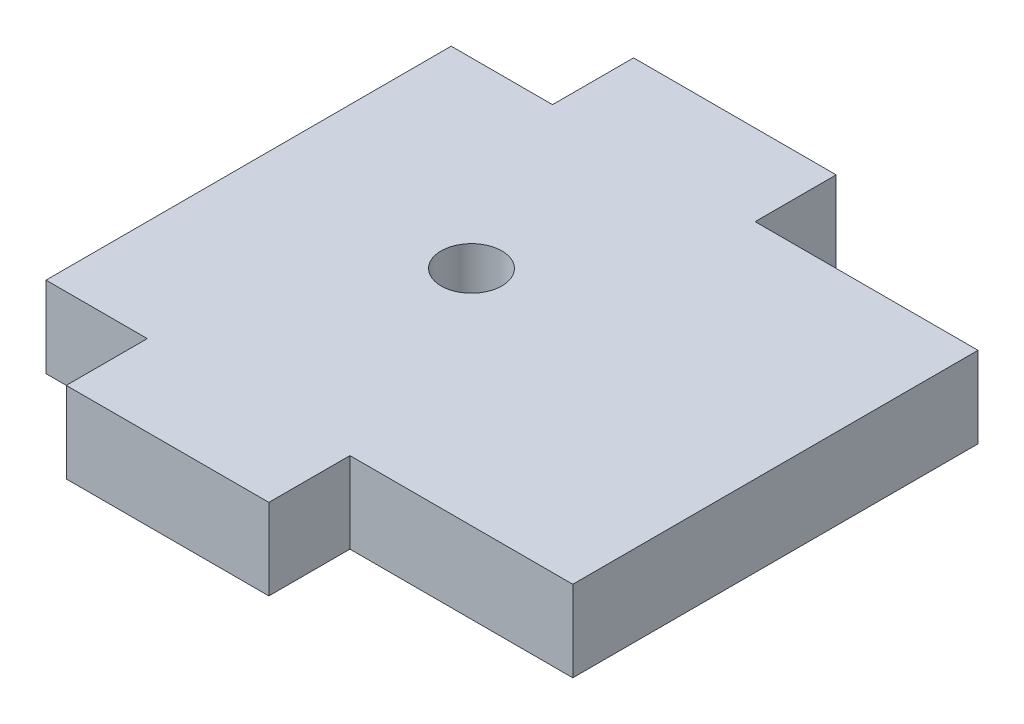
from build123d import *

# Parameters (mm, degrees)
SKETCH1_R           = 1.5
BOSS_EXTRUDE2_DEPTH = 4


with BuildPart() as part:
    # Sketch1 → Boss-Extrude2 (new body)
    with BuildSketch(Plane(origin=(0, 0, 0), x_dir=(1, 0, 0), z_dir=(0, 1, 0))):
        Polygon((15, 20), (26, 20), (26, 0), (15, 0), (15, -4), (5, -4), (5, 0), (0, 0), (0, 20), (5, 20), (5, 24), (15, 24), align=None)
        with Locations((10, 11)):
            Circle(SKETCH1_R, mode=Mode.SUBTRACT)
    extrude(amount=BOSS_EXTRUDE2_DEPTH)


solid = part.part
